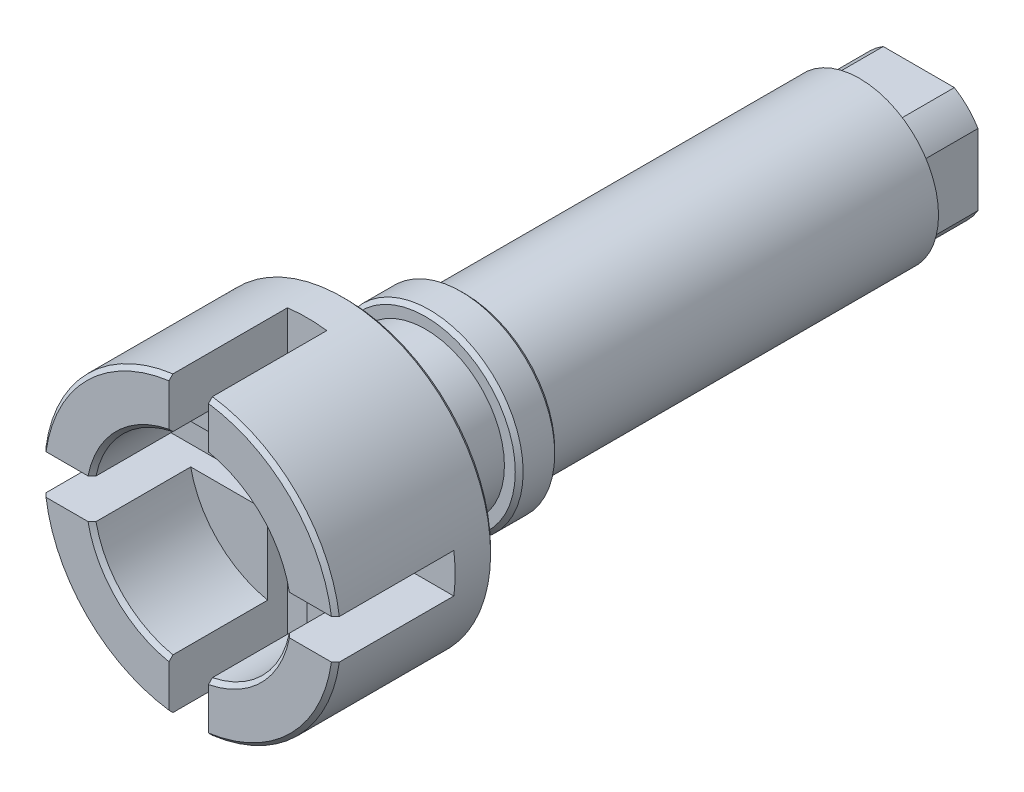
from build123d import *

# Parameters (mm, degrees)
SKETCH1_R                 = 7.5
BOSS_EXTRUDE1_DEPTH       = 37
SKETCH2_W                 = 3.5
SKETCH2_H                 = 29
CUT_EXTRUDE1_DEPTH        = 6
CUT_EXTRUDE2_DEPTH        = 6
SKETCH6_R                 = 5
CUT_EXTRUDE3_DEPTH        = 5
SKETCH10_OUTSIDE_W        = 25.53
SKETCH10_OUTSIDE_H        = 25.53
SKETCH10_OUTSIDE_W_2      = 6
SKETCH10_OUTSIDE_H_2      = 6
CUT_EXTRUDE4_DEPTH        = 3
SKETCH19_R                = 4.909942114
SKETCH19_R_2              = 3.5
CUT_EXTRUDE5_DEPTH        = 4
M4X0_7_TAPPED_HOLE1_D     = 3.3
M4X0_7_TAPPED_HOLE1_DEPTH = 10.1
M4X0_7_TAPPED_HOLE1_TIP   = 0.991420021
SKETCH17_W                = 0.75
SKETCH17_H                = 2
CHAMFER1_SIZE             = 0.2
CHAMFER2_SIZE             = 0.2


with BuildPart() as part:
    # Sketch1 → Boss-Extrude1 (new body)
    with BuildSketch(Plane.XY):
        Circle(SKETCH1_R)
    extrude(amount=-BOSS_EXTRUDE1_DEPTH)

    # Sketch2 → Cut-Revolve1 (revolve, cut)
    with BuildSketch(Plane(origin=(0, 0, 0), x_dir=(1, 0, 0), z_dir=(0, 1, 0))):
        with Locations((5.75, 22.5)):
            Rectangle(SKETCH2_W, SKETCH2_H)
    revolve(axis=Axis((0, 0, 0), (0, 0, -1)), mode=Mode.SUBTRACT)

    # Sketch4 → Cut-Extrude1 (cut)
    with BuildSketch(Plane.XY):
        with BuildLine():
            Line((-9.646529656, 1), (9.646529656, 1))
            ThreePointArc((9.646529656, 1), (10.646529656, 0), (9.646529656, -1))
            Line((9.646529656, -1), (-9.646529656, -1))
            ThreePointArc((-9.646529656, -1), (-10.646529656, 0), (-9.646529656, 1))
        make_face()
    extrude(amount=-CUT_EXTRUDE1_DEPTH, mode=Mode.SUBTRACT)

    # Sketch5 → Cut-Extrude2 (cut)
    with BuildSketch(Plane.XY):
        with BuildLine():
            Line((1, 8.5), (1, -8.5))
            ThreePointArc((1, -8.5), (0, -9.5), (-1, -8.5))
            Line((-1, -8.5), (-1, 8.5))
            ThreePointArc((-1, 8.5), (0, 9.5), (1, 8.5))
        make_face()
    extrude(amount=-CUT_EXTRUDE2_DEPTH, mode=Mode.SUBTRACT)

    # Sketch6 → Cut-Extrude3 (cut)
    with BuildSketch(Plane.XY):
        Circle(SKETCH6_R)
    extrude(amount=-CUT_EXTRUDE3_DEPTH, mode=Mode.SUBTRACT)

    # Sketch10 outside → Cut-Extrude4 (cut)
    with BuildSketch(Plane(origin=(0, 0, -37), x_dir=(-1, 0, 0), z_dir=(0, 0, -1))):
        Rectangle(SKETCH10_OUTSIDE_W, SKETCH10_OUTSIDE_H)
        Rectangle(SKETCH10_OUTSIDE_W_2, SKETCH10_OUTSIDE_H_2, mode=Mode.SUBTRACT)
    extrude(amount=-CUT_EXTRUDE4_DEPTH, mode=Mode.SUBTRACT)

    # Sketch19 → Cut-Extrude5 (cut, through all)
    with BuildSketch(Plane(origin=(0, 0, -34), x_dir=(-1, 0, 0), z_dir=(0, 0, -1))):
        Circle(SKETCH19_R)
        Circle(SKETCH19_R_2, mode=Mode.SUBTRACT)
    extrude(amount=CUT_EXTRUDE5_DEPTH, mode=Mode.SUBTRACT)

    # M4x0.7 Tapped Hole1
    with Locations(Plane(origin=(0, 0, -37), x_dir=(-1, 0, 0), z_dir=(0, 0, -1))):
        with Locations((0, 0)):
            Hole(M4X0_7_TAPPED_HOLE1_D / 2, depth=M4X0_7_TAPPED_HOLE1_DEPTH)
            with Locations((0, 0, -(M4X0_7_TAPPED_HOLE1_DEPTH + M4X0_7_TAPPED_HOLE1_TIP / 2))):  # 118° drill point
                Cone(0, M4X0_7_TAPPED_HOLE1_D / 2, M4X0_7_TAPPED_HOLE1_TIP, mode=Mode.SUBTRACT)

    # Sketch17 → Revolve1 (revolve)
    with BuildSketch(Plane(origin=(0, 0, 0), x_dir=(1, 0, 0), z_dir=(0, 1, 0))):
        with Locations((4.375, 13)):
            Rectangle(SKETCH17_W, SKETCH17_H)
    revolve(axis=Axis((0, 0, 0), (0, 0, -1)))

    # Chamfer1
    chamfer1_edges = [part.edges().sort_by_distance(p)[0] for p in [
        (-4.75, 0, -12),
        (-4.75, 0, -14),
    ]]
    chamfer(chamfer1_edges, length=CHAMFER1_SIZE)

    # Chamfer2
    chamfer2_edges = [part.edges().sort_by_distance(p)[0] for p in [
        (-5.303300859, -5.303300859, 0),
        (5.303300859, 5.303300859, 0),
        (5.303300859, -5.303300859, 0),
        (-5.303300859, 5.303300859, 0),
        (-7.5, 0, -8),
        (-3.535533906, -3.535533906, 0),
        (3.535533906, -3.535533906, 0),
        (3.535533906, 3.535533906, 0),
        (-3.535533906, 3.535533906, 0),
    ]]
    chamfer(chamfer2_edges, length=CHAMFER2_SIZE)


solid = part.part
